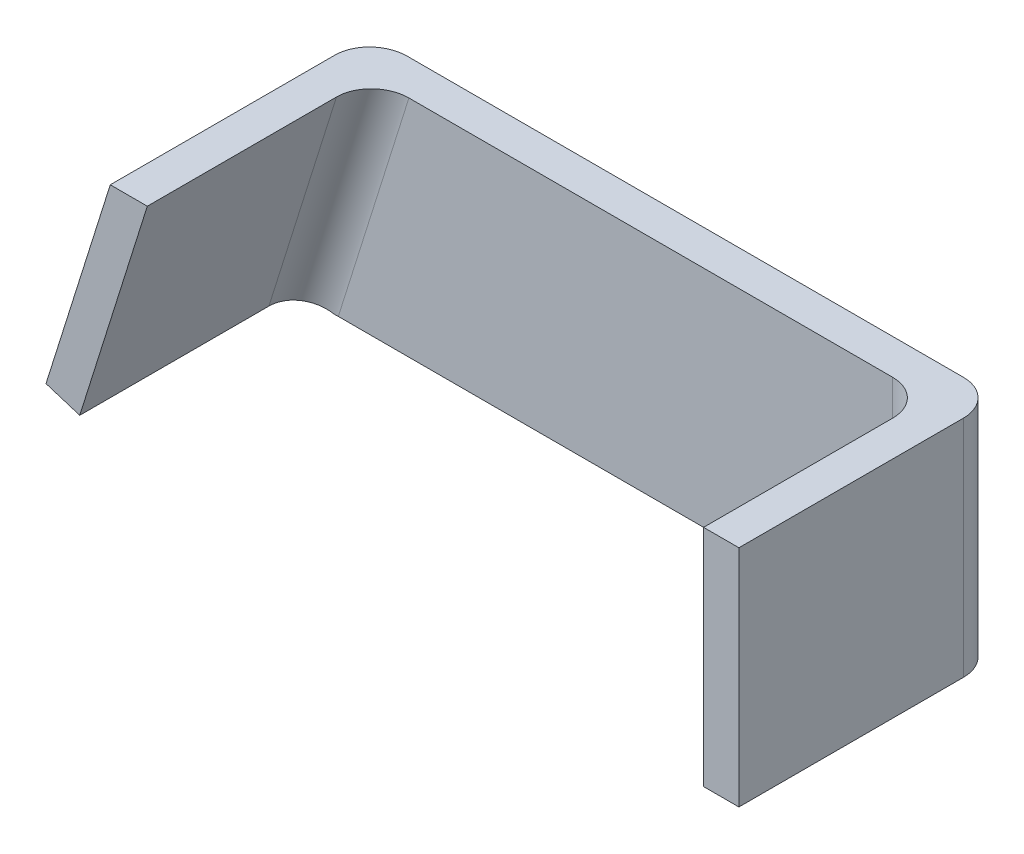
from build123d import *

# Parameters (mm, degrees)
BOSS_EXTRUDE1_DEPTH = 5
BOSS_EXTRUDE2_DEPTH = 31.75
FILLET1_R           = 5
FILLET4_R           = 5


with BuildPart() as part:
    # Sketch1 → Boss-Extrude1 (new body)
    with BuildSketch(Plane.XY):
        Polygon((-44.432958232964275, 15.875000000000018), (44.46704176703572, 15.875000000000021), (44.467041767035624, -15.874999999999979), (-44.43295823296417, -15.875000000000448), (-53.51922912646058, -13.017500000000476), align=None)
    extrude(amount=BOSS_EXTRUDE1_DEPTH)

    # Sketch2 → Boss-Extrude2 (add)
    with BuildSketch(Plane.XY.offset(5)):
        Polygon((-48.74953311937584, -14.517500000000437), (-53.51922912646058, -13.017500000000476), (-44.432958232964275, 15.875000000000018), (-39.19153404935471, 15.875000000000021), align=None)
        Polygon((39.467041767035624, -15.875000000000448), (39.467041767035624, 15.875000000000021), (44.46704176703572, 15.875000000000021), (44.467041767035624, -15.874999999999979), align=None)
    extrude(amount=BOSS_EXTRUDE2_DEPTH)

    # Fillet1
    fillet1_edges = [part.edges().sort_by_distance(p)[0] for p in [
        (-48.97609367971243, 1.4287499999997717, 0),
    ]]
    fillet(fillet1_edges, radius=FILLET1_R)

    # Fillet4
    fillet4_edges = [part.edges().sort_by_distance(p)[0] for p in [
        (44.46704176703567, 2.132e-14, 0),
        (39.467041767035624, -2.1316e-13, 5),
        (-43.97053358436527, 0.6787499999997912, 5),
    ]]
    fillet(fillet4_edges, radius=FILLET4_R)


solid = part.part
